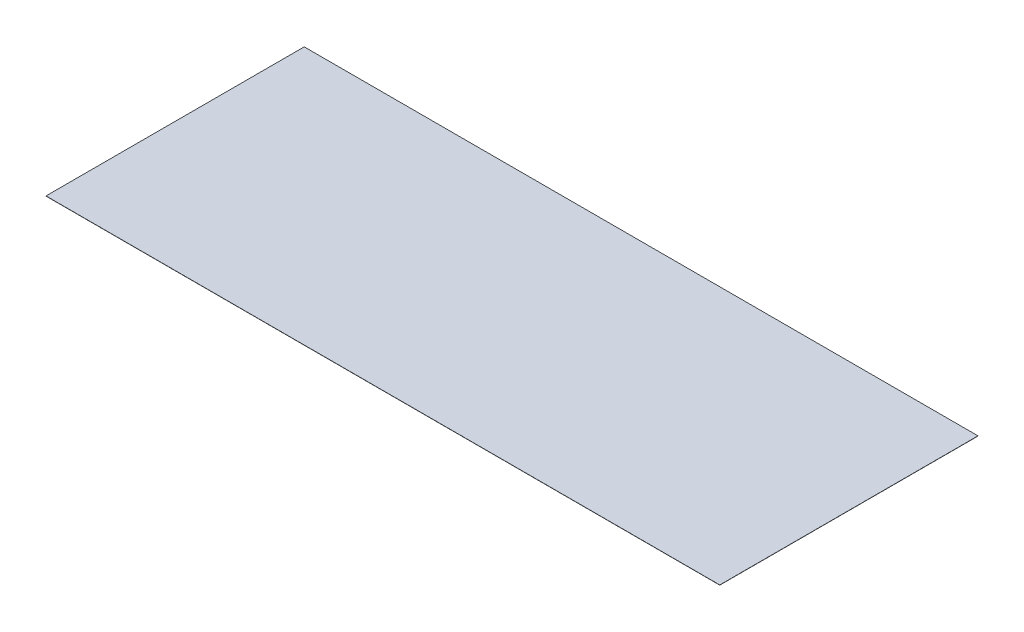
from build123d import *

# Parameters (mm, degrees)
SKETCH1_W           = 5486.4
SKETCH1_H           = 2102.612
BOSS_EXTRUDE1_DEPTH = 1.5875


with BuildPart() as part:
    # Sketch1 → Boss-Extrude1 (new body)
    with BuildSketch(Plane(origin=(0, 0, 0), x_dir=(1, 0, 0), z_dir=(0, 1, 0))):
        Rectangle(SKETCH1_W, SKETCH1_H)
    extrude(amount=BOSS_EXTRUDE1_DEPTH)


solid = part.part
